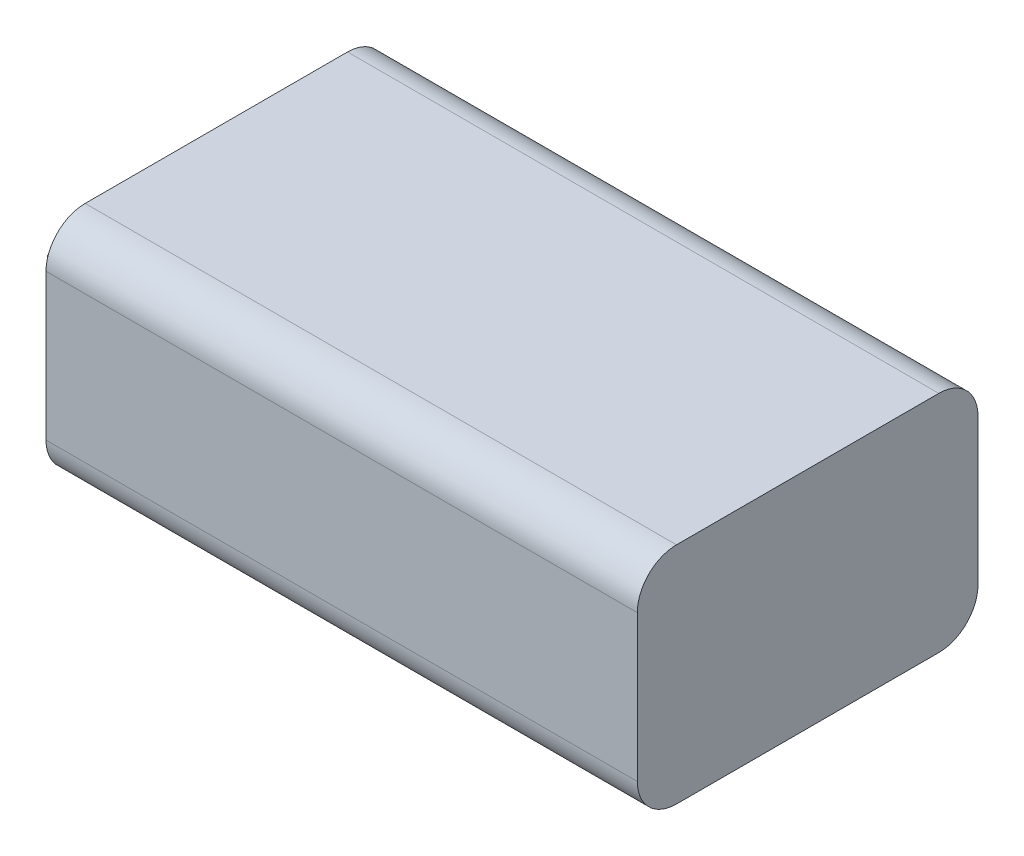
from build123d import *

# Parameters (mm, degrees)
BOSS_EXTRUDE1_DEPTH = 17.2
FILLET1_R           = 3
BOSS_EXTRUDE2_START = 4
SKETCH1_3_W         = 2.7
SKETCH1_3_H         = 19.5
BOSS_EXTRUDE2_DEPTH = 8.5


with BuildPart() as part:
    # Sketch1 → Boss-Extrude1 (new body)
    with BuildSketch(Plane(origin=(0, 0, 0), x_dir=(1, 0, 0), z_dir=(0, 1, 0))):
        Polygon((-32.206070131, -7.025882353), (-32.206070131, -9.825882353), (13.093929869, -9.825882353), (13.093929869, 16.274117647), (-32.206070131, 16.274117647), (-32.206070131, 12.474117647), align=None)
    extrude(amount=BOSS_EXTRUDE1_DEPTH)

    # Fillet1
    fillet1_edges = [part.edges().sort_by_distance(p)[0] for p in [
        (-9.556070131, 17.2, -16.274117647),
        (-9.556070131, 0, -16.274117647),
        (-9.556070131, 0, 9.825882353),
        (-9.556070131, 17.2, 9.825882353),
    ]]
    fillet(fillet1_edges, radius=FILLET1_R)

    # Sketch1_3 → Boss-Extrude2 (add)
    with BuildSketch(Plane(origin=(0, 0, 0), x_dir=(1, 0, 0), z_dir=(0, 1, 0)).offset(BOSS_EXTRUDE2_START)):
        with Locations((-33.556070131, 2.724117647)):
            Rectangle(SKETCH1_3_W, SKETCH1_3_H)
    extrude(amount=BOSS_EXTRUDE2_DEPTH)


solid = part.part
